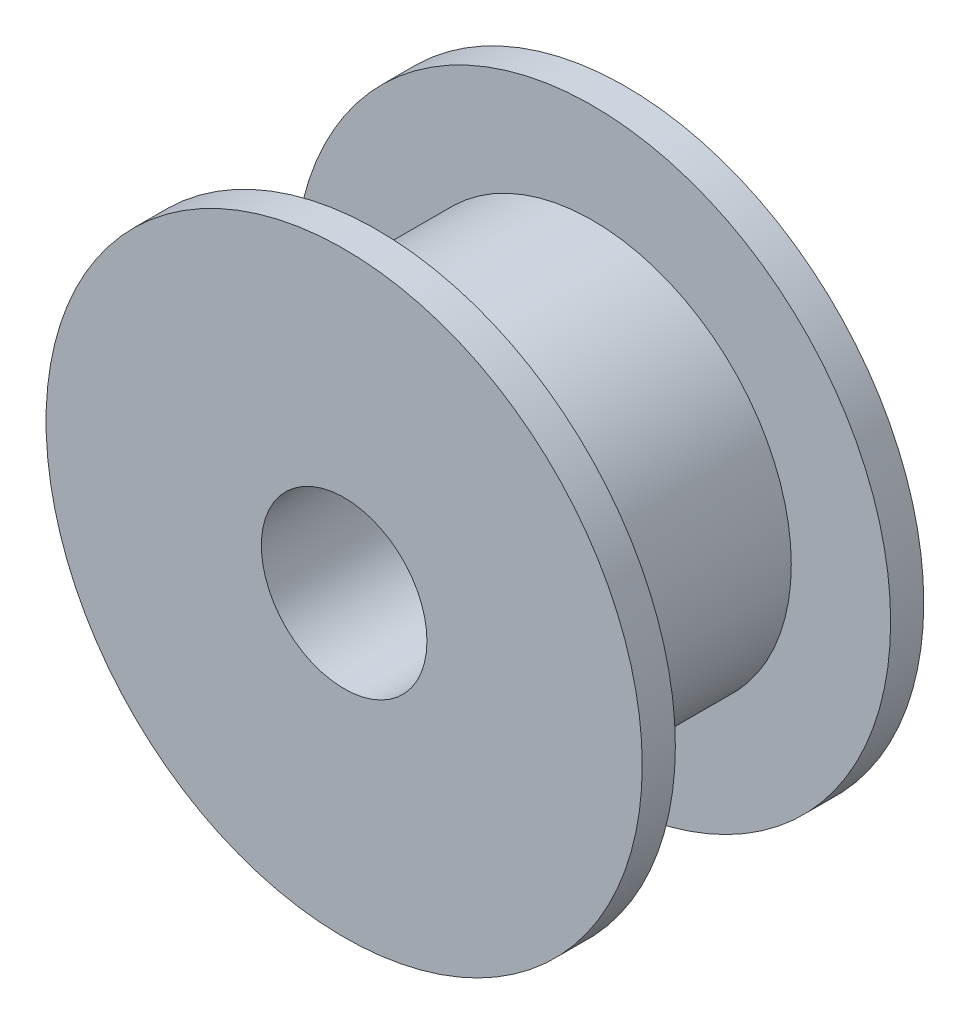
from build123d import *

# Parameters (mm, degrees)
SKETCH_1_R          = 9
EXTRUDE_1_DEPTH     = 1
SKETCH_2_R          = 6
EXTRUDE_2_DEPTH     = 6.5
SKETCH_3_R          = 9
EXTRUDE_3_DEPTH     = 1
SKETCH_4_R          = 2.5
CUT_EXTRUDE_1_DEPTH = 9.5


with BuildPart() as part:
    # 草图1 → 凸台-拉伸1 (new body)
    with BuildSketch(Plane.XY):
        Circle(SKETCH_1_R)
    extrude(amount=EXTRUDE_1_DEPTH)

    # 草图2 → 凸台-拉伸2 (add)
    with BuildSketch(Plane.XY.offset(1)):
        Circle(SKETCH_2_R)
    extrude(amount=EXTRUDE_2_DEPTH)

    # 草图3 → 凸台-拉伸3 (add)
    with BuildSketch(Plane.XY.offset(7.5)):
        Circle(SKETCH_3_R)
    extrude(amount=EXTRUDE_3_DEPTH)

    # 草图4 → 切除-拉伸1 (cut, through all)
    with BuildSketch(Plane.XY.offset(8.5)):
        Circle(SKETCH_4_R)
    extrude(amount=-CUT_EXTRUDE_1_DEPTH, mode=Mode.SUBTRACT)


solid = part.part
